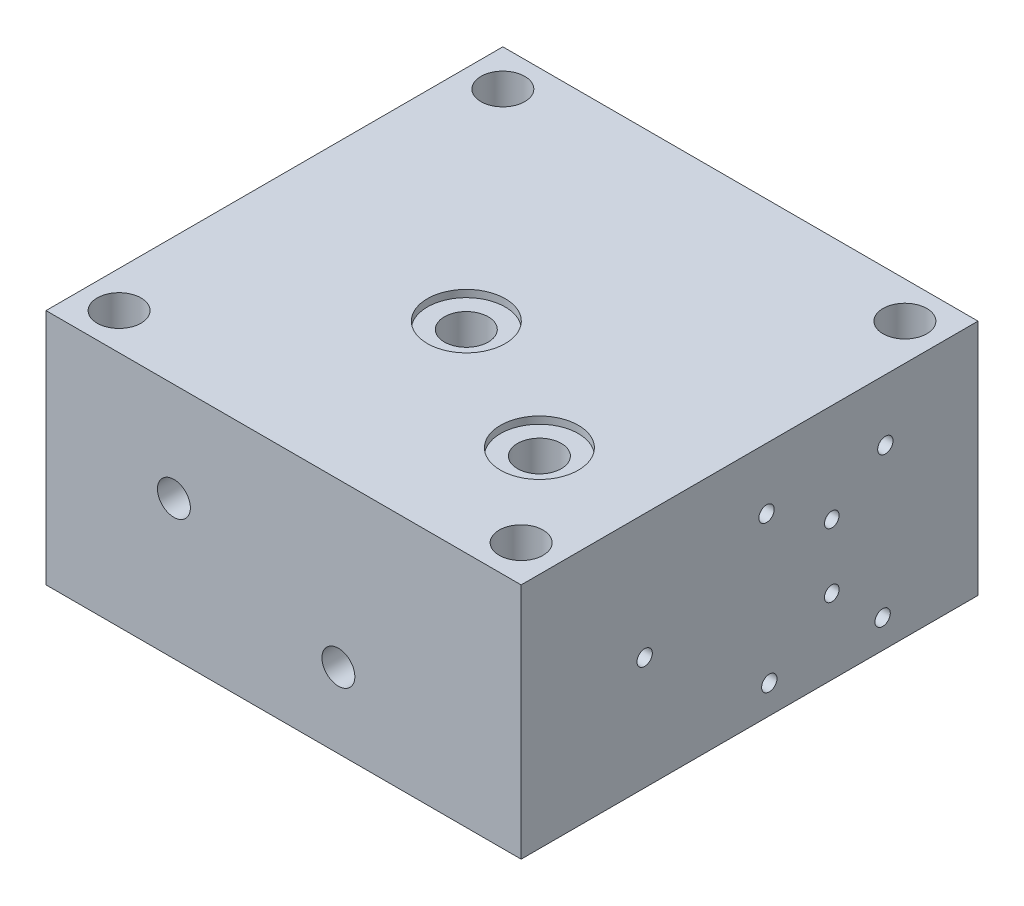
from build123d import *

# Parameters (mm, degrees)
SKETCH_2_W                 = 130
SKETCH_2_H                 = 125
SKETCH_2_R                 = 6
EXTRUDE_1_DEPTH            = 65
HOLE_WIZARD_4_0_4_5_D      = 4
HOLE_WIZARD_M5_3_D         = 4.2
HOLE_WIZARD_M5_3_DEPTH     = 12
HOLE_WIZARD_M5_3_TIP       = 1.2618073
HOLE_WIZARD_4_0_4_9_D      = 4
HOLE_WIZARD_4_0_4_9_DEPTH  = 32.5
HOLE_WIZARD_4_0_4_9_TIP    = 1.201721238
HOLE_WIZARD_6_0_6_1_D      = 6
HOLE_WIZARD_6_0_6_1_DEPTH  = 42
HOLE_WIZARD_6_0_6_1_TIP    = 1.802581857
HOLE_WIZARD_M6_1_D         = 5
HOLE_WIZARD_M6_1_DEPTH     = 13
HOLE_WIZARD_M6_1_TIP       = 1.502151548
HOLE_WIZARD_4_0_4_11_D     = 4
HOLE_WIZARD_4_0_4_11_DEPTH = 85
HOLE_WIZARD_4_0_4_11_TIP   = 1.201721238
M10X1_0_1_D                = 9
M10X1_0_1_DEPTH            = 13
M10X1_0_1_TIP              = 2.703872786
HOLE_WIZARD_1_D            = 12
HOLE_WIZARD_1_DEPTH        = 65
HOLE_WIZARD_1_CBORE_D      = 21.3
HOLE_WIZARD_1_CBORE_DEPTH  = 1.97
HOLE_WIZARD_8_0_8_1_D      = 8
HOLE_WIZARD_8_0_8_1_DEPTH  = 15.5
HOLE_WIZARD_8_0_8_1_TIP    = 2.403442476
HOLE_WIZARD_M5_5_D         = 4.2
HOLE_WIZARD_M5_5_DEPTH     = 10
HOLE_WIZARD_M5_5_TIP       = 1.2618073
HOLE_WIZARD_6_0_6_2_D      = 6
HOLE_WIZARD_6_0_6_2_DEPTH  = 58.5
HOLE_WIZARD_6_0_6_2_TIP    = 1.802581857
HOLE_WIZARD_6_0_6_3_D      = 6
HOLE_WIZARD_6_0_6_3_DEPTH  = 90
HOLE_WIZARD_6_0_6_3_TIP    = 1.802581857
HOLE_WIZARD_M5_8_D         = 4.2
HOLE_WIZARD_M5_8_DEPTH     = 41.31
HOLE_WIZARD_M5_8_TIP       = 1.2618073
HOLE_WIZARD_6_0_6_4_D      = 6
M10X1_0_2_D                = 9
M10X1_0_2_DEPTH            = 13
M10X1_0_2_TIP              = 2.703872786


with BuildPart() as part:
    # 草图2 → 凸台-拉伸1 (new body)
    with BuildSketch(Plane(origin=(0, 0, 0), x_dir=(1, 0, 0), z_dir=(0, 1, 0))):
        Rectangle(SKETCH_2_W, SKETCH_2_H)
        with Locations((-55, 52.5)):
            Circle(SKETCH_2_R, mode=Mode.SUBTRACT)
        with Locations((55, 52.5)):
            Circle(SKETCH_2_R, mode=Mode.SUBTRACT)
        with Locations((55, -52.5)):
            Circle(SKETCH_2_R, mode=Mode.SUBTRACT)
        with Locations((-55, -52.5)):
            Circle(SKETCH_2_R, mode=Mode.SUBTRACT)
    extrude(amount=EXTRUDE_1_DEPTH)

    # Ø4.0 (4) 直径孔5 (through all)
    with Locations(Plane(origin=(-65, 38, -22.5), x_dir=(0, 0, -1), z_dir=(-1, 0, 0))):
        with Locations((0, 0)):
            Hole(HOLE_WIZARD_4_0_4_5_D / 2)

    # M5 螺纹孔3
    with Locations(Plane(origin=(65, 48.3, -4.65), x_dir=(0, 0, 1), z_dir=(1, 0, 0))):
        with Locations((0, 0), (-32.5, 0), (-31.75, 40.5), (-0.75, 40.5)):
            Hole(HOLE_WIZARD_M5_3_D / 2, depth=HOLE_WIZARD_M5_3_DEPTH)
            with Locations((0, 0, -(HOLE_WIZARD_M5_3_DEPTH + HOLE_WIZARD_M5_3_TIP / 2))):  # 118° drill point
                Cone(0, HOLE_WIZARD_M5_3_D / 2, HOLE_WIZARD_M5_3_TIP, mode=Mode.SUBTRACT)

    # Ø4.0 (4) 直径孔9
    with Locations(Plane(origin=(65, 20.5, -22.49541266), x_dir=(0, 0, 1), z_dir=(1, 0, 0))):
        with Locations((0, 0)):
            Hole(HOLE_WIZARD_4_0_4_9_D / 2, depth=HOLE_WIZARD_4_0_4_9_DEPTH)
            with Locations((0, 0, -(HOLE_WIZARD_4_0_4_9_DEPTH + HOLE_WIZARD_4_0_4_9_TIP / 2))):  # 118° drill point
                Cone(0, HOLE_WIZARD_4_0_4_9_D / 2, HOLE_WIZARD_4_0_4_9_TIP, mode=Mode.SUBTRACT)

    # Ø6.0 (6) 直径孔1
    with Locations(Plane(origin=(32.5, 20.5, -62.5), x_dir=(-1, 0, 0), z_dir=(0, 0, -1))):
        with Locations((0, 0)):
            Hole(HOLE_WIZARD_6_0_6_1_D / 2, depth=HOLE_WIZARD_6_0_6_1_DEPTH)
            with Locations((0, 0, -(HOLE_WIZARD_6_0_6_1_DEPTH + HOLE_WIZARD_6_0_6_1_TIP / 2))):  # 118° drill point
                Cone(0, HOLE_WIZARD_6_0_6_1_D / 2, HOLE_WIZARD_6_0_6_1_TIP, mode=Mode.SUBTRACT)

    # M6 螺纹孔1
    with Locations(Plane(origin=(-65, 52.5, -37), x_dir=(0, 0, -1), z_dir=(-1, 0, 0))):
        with Locations((0, 0), (-29, 0), (0, 29), (-29, 29)):
            Hole(HOLE_WIZARD_M6_1_D / 2, depth=HOLE_WIZARD_M6_1_DEPTH)
            with Locations((0, 0, -(HOLE_WIZARD_M6_1_DEPTH + HOLE_WIZARD_M6_1_TIP / 2))):  # 118° drill point
                Cone(0, HOLE_WIZARD_M6_1_D / 2, HOLE_WIZARD_M6_1_TIP, mode=Mode.SUBTRACT)

    # Ø4.0 (4) 直径孔11
    with Locations(Plane(origin=(-30, 38, 62.5), x_dir=(1, 0, 0), z_dir=(0, 0, 1))):
        with Locations((0, 0)):
            Hole(HOLE_WIZARD_4_0_4_11_D / 2, depth=HOLE_WIZARD_4_0_4_11_DEPTH)
            with Locations((0, 0, -(HOLE_WIZARD_4_0_4_11_DEPTH + HOLE_WIZARD_4_0_4_11_TIP / 2))):  # 118° drill point
                Cone(0, HOLE_WIZARD_4_0_4_11_D / 2, HOLE_WIZARD_4_0_4_11_TIP, mode=Mode.SUBTRACT)

    # M10x1.0 螺纹孔1
    with Locations(Plane(origin=(-30, 38, 62.5), x_dir=(1, 0, 0), z_dir=(0, 0, 1))):
        with Locations((0, 0)):
            Hole(M10X1_0_1_D / 2, depth=M10X1_0_1_DEPTH)
            with Locations((0, 0, -(M10X1_0_1_DEPTH + M10X1_0_1_TIP / 2))):  # 118° drill point
                Cone(0, M10X1_0_1_D / 2, M10X1_0_1_TIP, mode=Mode.SUBTRACT)

    # 孔1
    with Locations(Plane(origin=(-5, 65, 7.5), x_dir=(0, 0, 1), z_dir=(0, 1, 0))):
        with Locations((0, 0), (20, 40)):
            CounterBoreHole(HOLE_WIZARD_1_D / 2, HOLE_WIZARD_1_CBORE_D / 2, HOLE_WIZARD_1_CBORE_DEPTH, depth=HOLE_WIZARD_1_DEPTH)

    # Ø8.0 (8) 直径孔1
    with Locations(Plane(origin=(23, 0, -3.7), x_dir=(0, 0, -1), z_dir=(0, -1, 0))):
        with Locations((0, 0)):
            Hole(HOLE_WIZARD_8_0_8_1_D / 2, depth=HOLE_WIZARD_8_0_8_1_DEPTH)
            with Locations((0, 0, -(HOLE_WIZARD_8_0_8_1_DEPTH + HOLE_WIZARD_8_0_8_1_TIP / 2))):  # 118° drill point
                Cone(0, HOLE_WIZARD_8_0_8_1_D / 2, HOLE_WIZARD_8_0_8_1_TIP, mode=Mode.SUBTRACT)

    # M5 螺纹孔5
    with Locations(Plane(origin=(4.7, 36, -62.5), x_dir=(-1, 0, 0), z_dir=(0, 0, -1))):
        with Locations((0, 0), (-40.5, 0), (-40.5, -31), (0, -31)):
            Hole(HOLE_WIZARD_M5_5_D / 2, depth=HOLE_WIZARD_M5_5_DEPTH)
            with Locations((0, 0, -(HOLE_WIZARD_M5_5_DEPTH + HOLE_WIZARD_M5_5_TIP / 2))):  # 118° drill point
                Cone(0, HOLE_WIZARD_M5_5_D / 2, HOLE_WIZARD_M5_5_TIP, mode=Mode.SUBTRACT)

    # Ø6.0 (6) 直径孔2
    with Locations(Plane(origin=(23.7, 10.1, -62.5), x_dir=(-1, 0, 0), z_dir=(0, 0, -1))):
        with Locations((0, 0)):
            Hole(HOLE_WIZARD_6_0_6_2_D / 2, depth=HOLE_WIZARD_6_0_6_2_DEPTH)
            with Locations((0, 0, -(HOLE_WIZARD_6_0_6_2_DEPTH + HOLE_WIZARD_6_0_6_2_TIP / 2))):  # 118° drill point
                Cone(0, HOLE_WIZARD_6_0_6_2_D / 2, HOLE_WIZARD_6_0_6_2_TIP, mode=Mode.SUBTRACT)

    # Ø6.0 (6) 直径孔3
    with Locations(Plane(origin=(23.7, 30.9, -62.5), x_dir=(-1, 0, 0), z_dir=(0, 0, -1))):
        with Locations((0, 0)):
            Hole(HOLE_WIZARD_6_0_6_3_D / 2, depth=HOLE_WIZARD_6_0_6_3_DEPTH)
            with Locations((0, 0, -(HOLE_WIZARD_6_0_6_3_DEPTH + HOLE_WIZARD_6_0_6_3_TIP / 2))):  # 118° drill point
                Cone(0, HOLE_WIZARD_6_0_6_3_D / 2, HOLE_WIZARD_6_0_6_3_TIP, mode=Mode.SUBTRACT)

    # M5 螺纹孔8
    with Locations(Plane(origin=(65, 30.9, 28.70458734), x_dir=(0, 0, 1), z_dir=(1, 0, 0))):
        with Locations((0, 0)):
            Hole(HOLE_WIZARD_M5_8_D / 2, depth=HOLE_WIZARD_M5_8_DEPTH)
            with Locations((0, 0, -(HOLE_WIZARD_M5_8_DEPTH + HOLE_WIZARD_M5_8_TIP / 2))):  # 118° drill point
                Cone(0, HOLE_WIZARD_M5_8_D / 2, HOLE_WIZARD_M5_8_TIP, mode=Mode.SUBTRACT)

    # Ø6.0 (6) 直径孔4 (through all)
    with Locations(Plane(origin=(15, 20.5, -62.5), x_dir=(-1, 0, 0), z_dir=(0, 0, -1))):
        with Locations((0, 0)):
            Hole(HOLE_WIZARD_6_0_6_4_D / 2)

    # M10x1.0 螺纹孔2
    with Locations(Plane(origin=(15, 20.5, 62.5), x_dir=(1, 0, 0), z_dir=(0, 0, 1))):
        with Locations((0, 0)):
            Hole(M10X1_0_2_D / 2, depth=M10X1_0_2_DEPTH)
            with Locations((0, 0, -(M10X1_0_2_DEPTH + M10X1_0_2_TIP / 2))):  # 118° drill point
                Cone(0, M10X1_0_2_D / 2, M10X1_0_2_TIP, mode=Mode.SUBTRACT)


solid = part.part
